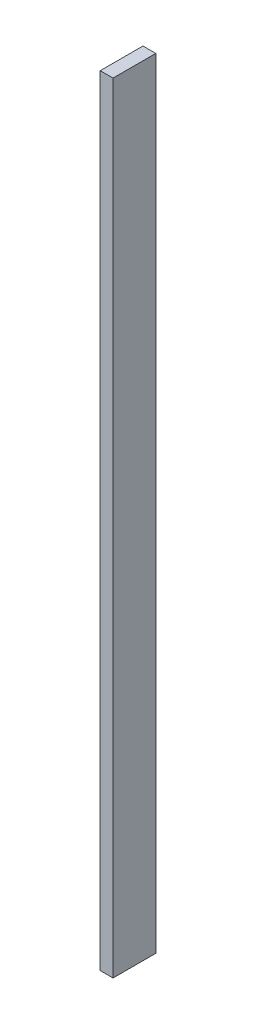
from build123d import *

# Parameters (mm, degrees)
SKIZZE1_W                       = 3
SKIZZE1_H                       = 10
AUFSATZ_LINEAR_AUSTRAGEN1_DEPTH = 182.4


with BuildPart() as part:
    # Skizze1 → Aufsatz-Linear austragen1 (new body)
    with BuildSketch(Plane(origin=(0, 0, 0), x_dir=(1, 0, 0), z_dir=(0, 1, 0))):
        Rectangle(SKIZZE1_W, SKIZZE1_H)
    extrude(amount=AUFSATZ_LINEAR_AUSTRAGEN1_DEPTH)


solid = part.part
